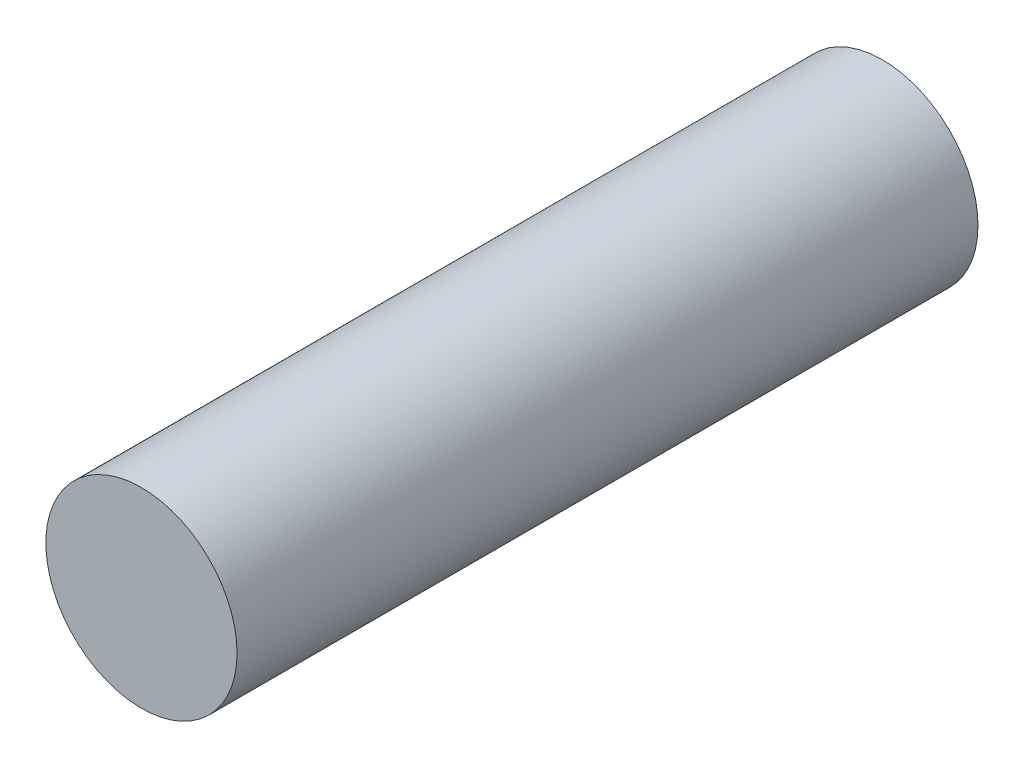
from build123d import *

# Parameters (mm, degrees)
SKETCH2_R           = 8
BOSS_EXTRUDE1_DEPTH = 62


with BuildPart() as part:
    # Sketch2 → Boss-Extrude1 (new body)
    with BuildSketch(Plane.XY):
        with Locations((-66.249466535, 32.884290271)):
            Circle(SKETCH2_R)
    extrude(amount=BOSS_EXTRUDE1_DEPTH)


solid = part.part
